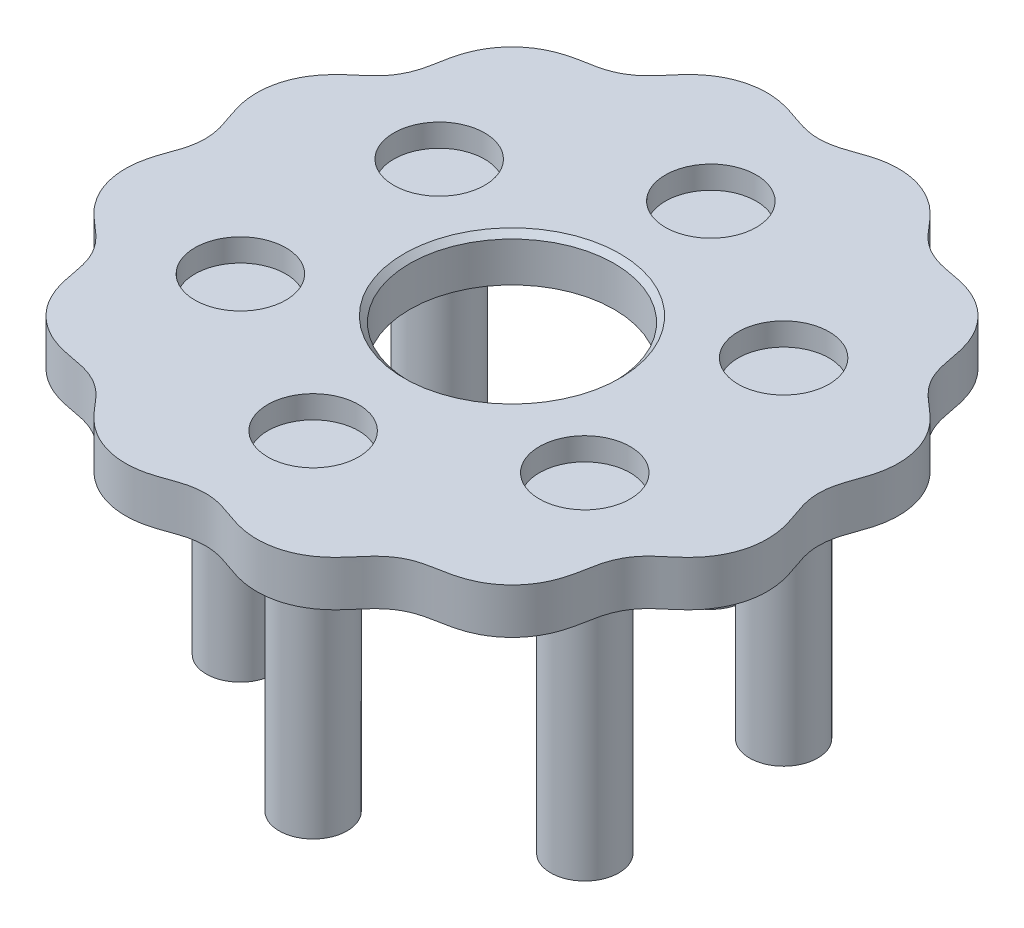
from build123d import *

# Parameters (mm, degrees)
BOSS_EXTRUDE1_DEPTH = 4
SKETCH2_R           = 9
CUT_EXTRUDE1_DEPTH  = 4
SKETCH3_R           = 4
CUT_EXTRUDE2_DEPTH  = 2
CHAMFER1_SIZE       = 0.5
SKETCH4_R           = 3
BOSS_EXTRUDE2_DEPTH = 25
FILLET1_R           = 1.5


with BuildPart() as part:
    # Sketch1 → Boss-Extrude1 (new body)
    with BuildSketch(Plane(origin=(0, 0, 0), x_dir=(1, 0, 0), z_dir=(0, 1, 0))):
        with BuildLine():
            add(Edge.make_bspline(
                [(27, 0), (27, -0.029843366), (27.000471765, -0.074622861), (27.002044312, -0.148526868), (27.00628274, -0.263641883), (27.012393312, -0.37537519), (27.022230728, -0.497376741), (27.03712787, -0.637409177), (27.055598892, -0.778657943), (27.077542429, -0.919236466), (27.10915909, -1.093914746), (27.153510714, -1.302382782), (27.213872001, -1.543652209), (27.292990208, -1.816594021), (27.380165946, -2.087067057), (27.473046955, -2.355596024), (27.59295323, -2.689915261), (27.737681672, -3.090771227), (27.896172741, -3.562218272), (28.063427098, -4.16720549), (28.192540962, -4.842140507), (28.27465216, -5.786972017), (28.188464813, -6.990666987), (27.810987259, -8.347530847), (27.084626542, -9.647288981), (26.186127024, -10.671759321), (25.238199473, -11.471905983), (24.372586568, -12.191039395), (23.620853175, -13.038066251), (23.063039846, -14.02515248), (22.723156568, -15.104958367), (22.540550691, -16.214937479), (22.311404563, -17.43453731), (21.855929835, -18.718964056), (21.078704809, -19.98167216), (19.944308098, -21.108107003), (18.676174537, -21.876448471), (17.388781942, -22.323268693), (16.168451287, -22.547256528), (15.058830974, -22.733329752), (13.981568641, -23.081976643), (12.999619336, -23.648776549), (12.158914933, -24.407246222), (11.442896635, -25.275122476), (10.638838498, -26.220033221), (9.608314539, -27.111685537), (8.308952362, -27.825947245), (6.766296625, -28.245380094), (5.284152953, -28.287347119), (3.944032474, -28.039779895), (2.773211959, -27.628533705), (1.720668629, -27.231619492), (0.615634296, -26.985876537), (-0.518110613, -26.975188118), (-1.627571272, -27.202504562), (-2.683196056, -27.592492668), (-3.85007581, -28.013459209), (-5.186489321, -28.279516523), (-6.675320744, -28.258945705), (-8.23569736, -27.856929805), (-9.556659448, -27.149289793), (-10.607747583, -26.253130508), (-11.424252904, -25.299053941), (-12.145498663, -24.42069207), (-12.993060357, -23.652288656), (-13.985080986, -23.079285719), (-15.074206005, -22.729094793), (-16.19549609, -22.543507448), (-17.430034502, -22.313659592), (-18.731806288, -21.851849103), (-20.00536007, -21.06206781), (-21.134053807, -19.912092302), (-21.896670407, -18.633242382), (-22.334837666, -17.34296826), (-22.553915449, -16.121964922), (-22.743815495, -15.012754256), (-23.101301577, -13.938157258), (-23.677046205, -12.961423213), (-24.442102548, -12.127035027), (-25.312028672, -11.413847459), (-26.253730695, -10.605690826), (-27.138488985, -9.569154166), (-27.843610955, -8.264810031), (-28.252168407, -6.719238227), (-28.283728903, -5.236836375), (-28.027183298, -3.898472997), (-27.611098664, -2.729600507), (-27.217360546, -1.675636661), (-26.980474187, -0.568422897), (-26.980139595, 0.565370052), (-27.216449027, 1.67272244), (-27.60997034, 2.726782849), (-28.02635931, 3.895531876), (-28.283483847, 5.233779265), (-28.252595633, 6.716195557), (-27.844741826, 8.261952815), (-27.140211848, 9.56661709), (-26.255901422, 10.60354088), (-25.314412694, 11.411968505), (-24.444361726, 12.124983159), (-23.678884788, 12.958963568), (-23.102563793, 13.935358019), (-22.744504016, 15.00977844), (-22.554344619, 16.118960967), (-22.335575088, 17.340005427), (-21.897967172, 18.63046337), (-21.135929645, 19.909659005), (-20.007760124, 21.060147962), (-18.734564151, 21.850507376), (-17.432988943, 22.312886202), (-16.19849739, 22.543076542), (-15.077182613, 22.728437444), (-13.987888625, 23.078054409), (-12.995530871, 23.650473301), (-12.147556588, 24.418443199), (-11.426126663, 25.29667015), (-10.609894266, 26.250958295), (-9.559200101, 27.147571895), (-8.238559851, 27.855810786), (-6.678365913, 28.258537364), (-5.189544443, 28.279782546), (-3.853010553, 28.014301607), (-2.686012173, 27.593622942), (-1.63049252, 27.203396622), (-0.521165891, 26.975495221), (0.612584807, 26.985514684), (1.717761904, 27.230689313), (2.77039276, 27.62740848), (3.941085326, 28.038974558), (5.281094376, 28.287123159), (6.763256705, 28.245828875), (8.306103534, 27.827098161), (9.605789274, 27.113425941), (10.636703091, 26.222217097), (11.441020578, 25.277508431), (12.156847243, 24.409493008), (12.99714314, 23.650593216), (13.978757745, 23.083213842), (15.055851496, 22.733997898), (16.165446962, 22.547688138), (17.38582278, 22.324025244), (18.673404279, 21.877764394), (19.941886401, 21.109997947), (21.076795453, 19.984079854), (21.854593687, 18.721724418), (22.310627604, 17.43749212), (22.540115396, 16.217941522), (22.722509608, 15.107940943), (23.061829575, 14.027974655), (23.619060558, 13.040559519), (24.370354006, 12.193123574), (25.235812527, 11.473780228), (26.183929614, 10.673877959), (27.082867808, 9.649802868), (27.809790294, 8.350417847), (28.187877209, 6.993819653), (28.274636512, 5.79026898), (28.193001106, 4.845542448), (28.064221926, 4.170608775), (27.897237423, 3.565701085), (27.716272452, 3.02678805), (27.521000906, 2.493508038), (27.356073412, 2.02396201), (27.232171798, 1.616745756), (27.145764302, 1.271144393), (27.08843343, 0.99468093), (27.044236171, 0.710209832), (27.019803238, 0.486134544), (27.007926019, 0.3061854), (27.002159239, 0.152753864), (27.000530427, 0.078733201), (27.000024448, 0.033939281), (27.000001572, 0.004099997)],
                knots=[0.079864449, 0.079864449, 0.079864449, 0.079864449, 0.079864449, 0.080511163, 0.080834519, 0.081157876, 0.08180459, 0.082451303, 0.083098017, 0.08374473, 0.084391444, 0.085038157, 0.086331585, 0.087625012, 0.088918439, 0.090211866, 0.091505293, 0.09279872, 0.095385574, 0.097972428, 0.100559282, 0.104219943, 0.107880604, 0.115201926, 0.122411059, 0.129620192, 0.134741434, 0.139862677, 0.144983919, 0.150105161, 0.155226231, 0.160347302, 0.165468372, 0.170589442, 0.177798511, 0.18500758, 0.192216685, 0.19942579, 0.204546942, 0.209668094, 0.214789247, 0.219910399, 0.225031553, 0.230152708, 0.235273862, 0.240395016, 0.247604122, 0.254813227, 0.262022295, 0.269231363, 0.274352432, 0.279473501, 0.284594569, 0.289715638, 0.294836882, 0.299958126, 0.30507937, 0.310200614, 0.317409748, 0.324618882, 0.331940203, 0.339261523, 0.344435233, 0.349608942, 0.354782652, 0.359956361, 0.365130069, 0.370303776, 0.375477483, 0.38065119, 0.387972512, 0.395293835, 0.402502968, 0.409712101, 0.414833341, 0.419954581, 0.425075821, 0.430197061, 0.435318133, 0.440439206, 0.445560278, 0.45068135, 0.457890419, 0.465099489, 0.472308593, 0.479517697, 0.484638848, 0.489759998, 0.494881149, 0.500002299, 0.505123455, 0.510244612, 0.515365768, 0.520486924, 0.52769603, 0.534905136, 0.542114203, 0.54932327, 0.554444337, 0.559565405, 0.564686472, 0.569807539, 0.574928785, 0.580050031, 0.585171277, 0.590292522, 0.597501657, 0.604710791, 0.612032111, 0.619353431, 0.624527142, 0.629700852, 0.634874563, 0.640048273, 0.64522198, 0.650395686, 0.655569392, 0.660743098, 0.668064421, 0.675385744, 0.682594876, 0.689804009, 0.694925247, 0.700046485, 0.705167724, 0.710288962, 0.715410036, 0.72053111, 0.725652183, 0.730773257, 0.737982327, 0.745191398, 0.752400501, 0.759609605, 0.764730753, 0.769851902, 0.774973051, 0.780094199, 0.785215357, 0.790336515, 0.795457673, 0.800578831, 0.807787938, 0.814997045, 0.822206111, 0.829415177, 0.834536243, 0.839657309, 0.844778374, 0.84989944, 0.855020687, 0.860141935, 0.865263183, 0.870384431, 0.877593566, 0.8848027, 0.892123013, 0.895783169, 0.899443325, 0.902029826, 0.904616328, 0.907202829, 0.90978933, 0.912375831, 0.913669081, 0.914962332, 0.916255583, 0.917548833, 0.918842084, 0.919165396, 0.919488709, 0.920135334, 0.920135334, 0.920135334, 0.920135334, 0.920135334], degree=4))
            Line((27.000001572, 0.004099997), (27, 0))
        make_face()
    extrude(amount=BOSS_EXTRUDE1_DEPTH)

    # Sketch2 → Cut-Extrude1 (cut)
    with BuildSketch(Plane(origin=(0, 4, 0), x_dir=(1, 0, 0), z_dir=(0, 1, 0))):
        with Locations(Location((0, 0, 0), (0, 0, 270))):
            Circle(SKETCH2_R)
    extrude(amount=-CUT_EXTRUDE1_DEPTH, mode=Mode.SUBTRACT)

    # Sketch3 → Cut-Extrude2 (cut)
    with BuildSketch(Plane(origin=(0, 4, 0), x_dir=(1, 0, 0), z_dir=(0, 1, 0))):
        with Locations(Location((0, 17.5, 0), (0, 0, 270))):
            Circle(SKETCH3_R)
        with Locations(Location((15.155444566, 8.75, 0), (0, 0, 270))):
            Circle(SKETCH3_R)
        with Locations(Location((15.155444566, -8.75, 0), (0, 0, 270))):
            Circle(SKETCH3_R)
        with Locations(Location((0, -17.5, 0), (0, 0, 270))):
            Circle(SKETCH3_R)
        with Locations(Location((-15.155444566, -8.75, 0), (0, 0, 270))):
            Circle(SKETCH3_R)
        with Locations(Location((-15.155444566, 8.75, 0), (0, 0, 270))):
            Circle(SKETCH3_R)
    extrude(amount=-CUT_EXTRUDE2_DEPTH, mode=Mode.SUBTRACT)

    # Chamfer1
    chamfer1_edges = [part.edges().sort_by_distance(p)[0] for p in [
        (0, 4, -9),
    ]]
    chamfer(chamfer1_edges, length=CHAMFER1_SIZE)

    # Sketch4 → Boss-Extrude2 (add)
    with BuildSketch(Plane.XZ):
        with Locations(Location((0, 17.5, 0), (0, 0, 270))):
            Circle(SKETCH4_R)
        with Locations(Location((15.155444566, 8.75, 0), (0, 0, 270))):
            Circle(SKETCH4_R)
        with Locations(Location((15.155444566, -8.75, 0), (0, 0, 270))):
            Circle(SKETCH4_R)
        with Locations(Location((0, -17.5, 0), (0, 0, 270))):
            Circle(SKETCH4_R)
        with Locations(Location((-15.155444566, -8.75, 0), (0, 0, 270))):
            Circle(SKETCH4_R)
        with Locations(Location((-15.155444566, 8.75, 0), (0, 0, 270))):
            Circle(SKETCH4_R)
    extrude(amount=BOSS_EXTRUDE2_DEPTH)

    # Fillet1
    fillet1_edges = [part.edges().sort_by_distance(p)[0] for p in [
        (0, 0, 20.5),
        (-15.155444566, 0, 11.75),
        (-15.155444566, 0, -5.75),
        (0, 0, -14.5),
        (15.155444566, 0, -5.75),
        (15.155444566, 0, 11.75),
    ]]
    fillet(fillet1_edges, radius=FILLET1_R)


solid = part.part
